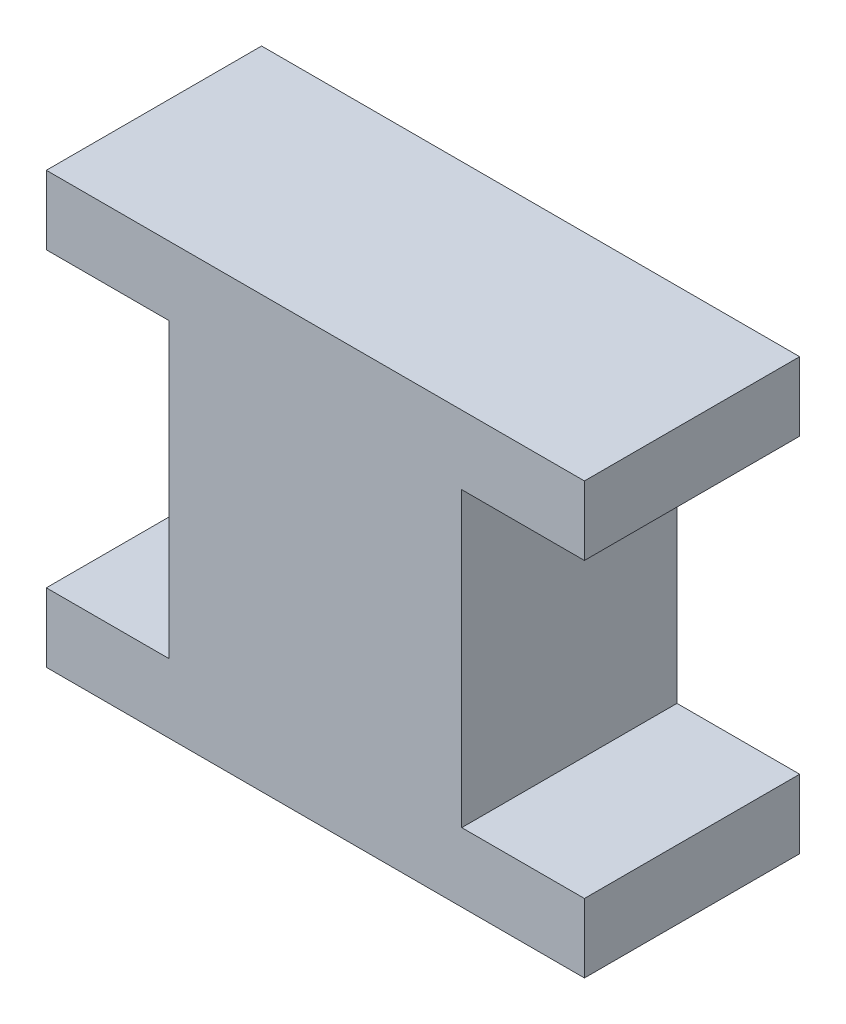
from build123d import *

# Parameters (mm, degrees)
BOSS_EXTRUDE1_DEPTH = 5.08


with BuildPart() as part:
    # Sketch1 → Boss-Extrude1 (new body)
    with BuildSketch(Plane.XY):
        Polygon((-3.4544, 3.4544), (-3.4544, -3.4544), (-6.35, -3.4544), (-6.35, -5.08), (6.35, -5.08), (6.35, -3.4544), (3.4544, -3.4544), (3.4544, 3.4544), (6.35, 3.4544), (6.35, 5.08), (-6.35, 5.08), (-6.35, 3.4544), align=None)
    extrude(amount=BOSS_EXTRUDE1_DEPTH)


solid = part.part
